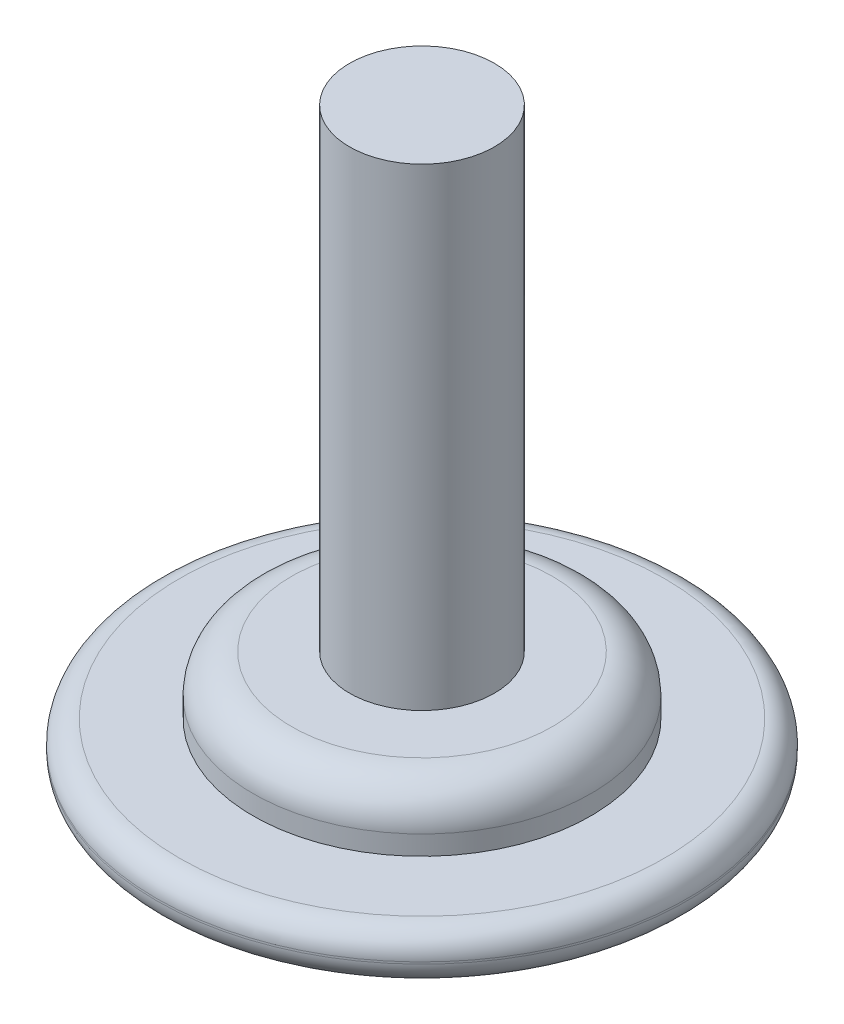
from build123d import *

# Parameters (mm, degrees)
FILLET2_R = 1.524
FILLET3_R = 2.54


with BuildPart() as part:
    # Sketch1 → Base-Revolve (revolve)
    with BuildSketch(Plane.XY):
        Polygon((0, 0), (0, 38.1), (-4.7625, 38.1), (-4.7625, 6.985), (-11.1125, 6.985), (-11.1125, 3.175), (-17.4625, 3.175), (-17.4625, 0), align=None)
    revolve(axis=Axis((0, 0, 0), (0, 1, 0)))

    # Fillet2
    fillet2_edges = [part.edges().sort_by_distance(p)[0] for p in [
        (17.4625, 3.175, 0),
        (17.4625, 0, 0),
    ]]
    fillet(fillet2_edges, radius=FILLET2_R)

    # Fillet3
    fillet3_edges = [part.edges().sort_by_distance(p)[0] for p in [
        (11.1125, 6.985, 0),
    ]]
    fillet(fillet3_edges, radius=FILLET3_R)


solid = part.part
